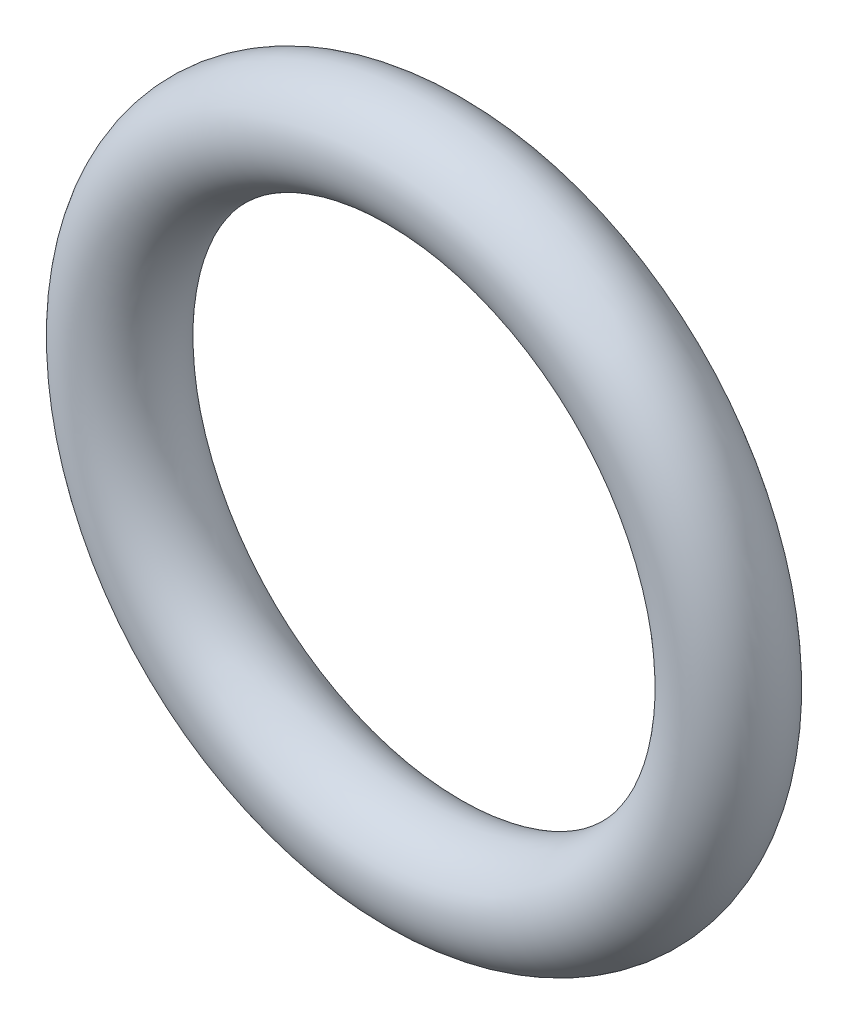
from build123d import *

# Parameters (mm, degrees)
SKETCH1_R = 2.28203125


with BuildPart() as part:
    # Sweep1: sweep along a path in Sketch2
    with BuildLine(Plane.XY) as sweep1_path:
        CenterArc((0, -13.39453125), 13.39453125, 0, 360)
    # Sketch1 → Sweep1 (sweep)
    with BuildSketch(Plane(origin=(0, 0, 0), x_dir=(0, 0, -1), z_dir=(1, 0, 0))):
        Circle(SKETCH1_R)
    sweep(path=sweep1_path.line)


solid = part.part
